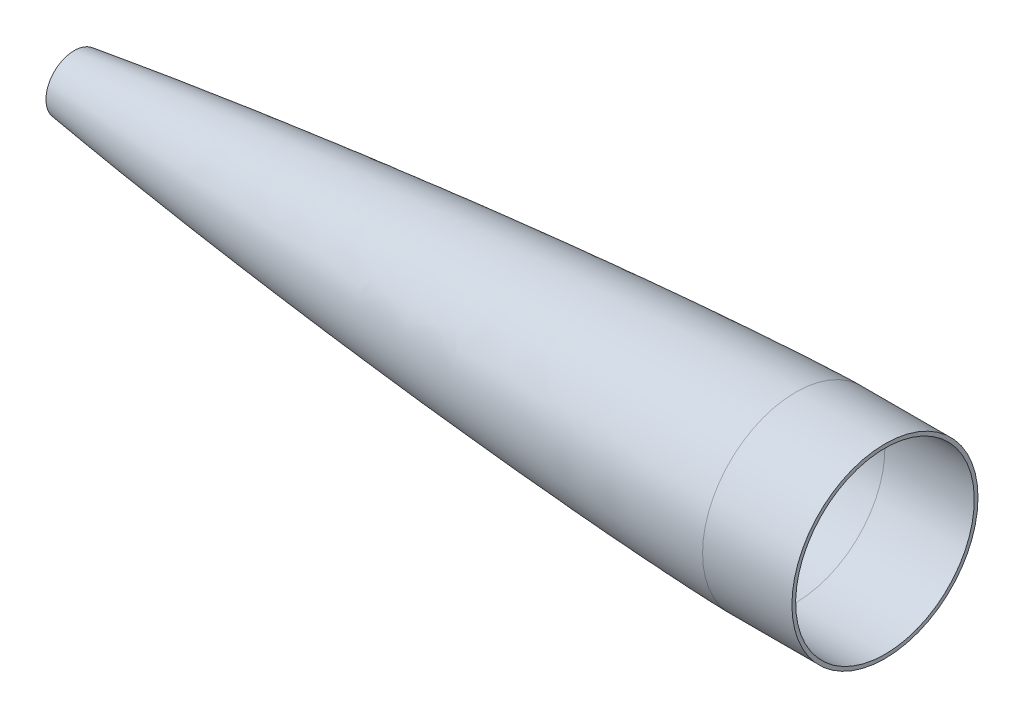
from build123d import *

# Parameters (mm, degrees)
SKETCH4_R          = 24.13
CUT_EXTRUDE1_DEPTH = 146.625635


with BuildPart() as part:
    # Sketch2 → Revolve2 (revolve)
    with BuildSketch(Plane.XY):
        with BuildLine():
            Line((0, 0), (2.600451681, 0))
            Line((2.600451681, 0), (146.625634978, 20.574))
            add(Edge.make_bspline(
                [(146.625634978, 20.574), (453.607635717, 56.392080036), (762, 76.2)],
                knots=[0, 0, 0, 1, 1, 1], degree=2))
            Line((762, 76.2), (838.2, 76.2))
            Line((838.2, 76.2), (838.2, 79.375))
            Line((838.2, 79.375), (762, 79.375))
            add(Edge.make_bspline(
                [(0, 0), (5.357571125, 1.097944906), (23.036237813, 4.588202882), (53.130005277, 9.975919363), (95.704545208, 16.826475489), (145.381989515, 24.073269594), (195.136255167, 30.767404326), (244.950093832, 37.001971717), (294.812163927, 42.836533029), (344.715569588, 48.306125066), (394.655306895, 53.432737483), (444.628105481, 58.226444193), (494.631614208, 62.688389905), (544.664401624, 66.809536286), (594.725704038, 70.56934063), (638.554311162, 73.50956517), (676.140102737, 75.737548675), (706.452486218, 77.30305593), (726.859894078, 78.222544099), (743.626304476, 78.864839271), (754.124654875, 79.190172124), (759.374629808, 79.325319355), (762, 79.375)],
                knots=[0.062743103, 0.062743103, 0.062743103, 0.062743103, 0.062743103, 0.089484674, 0.150853025, 0.212221372, 0.273589719, 0.334958066, 0.396326414, 0.457694762, 0.51906311, 0.580431457, 0.641799805, 0.703168154, 0.764536502, 0.825904849, 0.887273198, 0.917957372, 0.948641546, 0.974320773, 0.987160386, 1, 1, 1, 1, 1], degree=4))
        make_face()
    revolve(axis=Axis((0, 0, 0), (1, 0, 0)))

    # Sketch4 → Cut-Extrude1 (cut)
    with BuildSketch(Plane(origin=(0, 0, 0), x_dir=(0, 0, -1), z_dir=(1, 0, 0))):
        Circle(SKETCH4_R)
    extrude(amount=CUT_EXTRUDE1_DEPTH, mode=Mode.SUBTRACT)


solid = part.part
